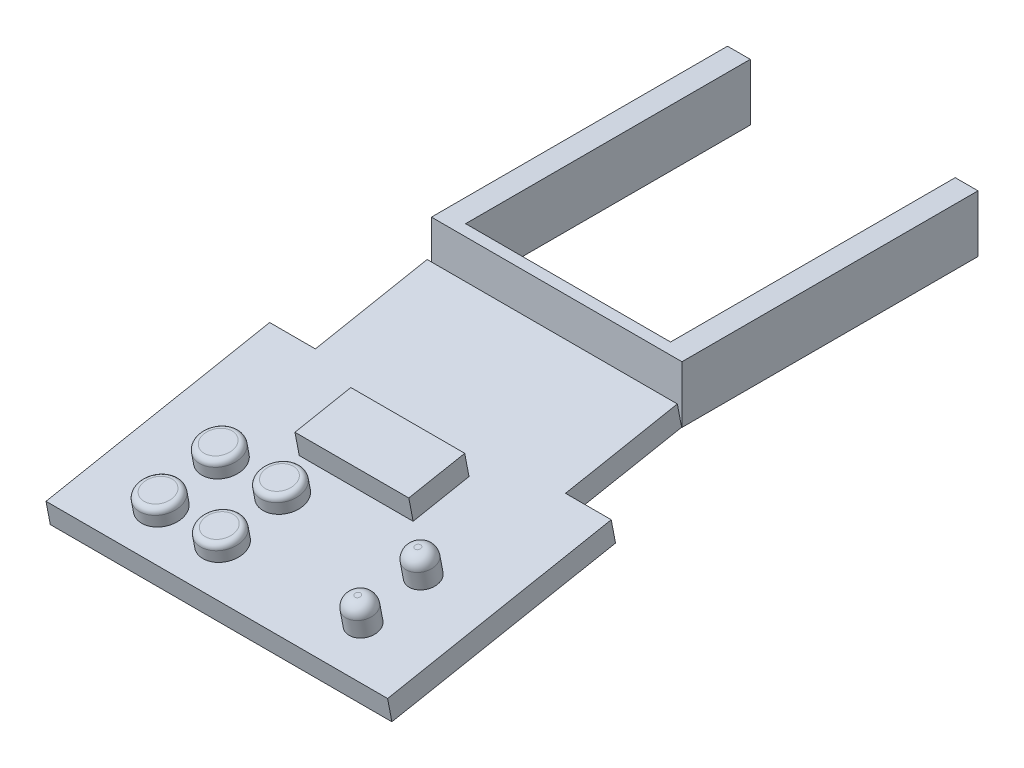
from build123d import *

# Parameters (mm, degrees)
SKETCH1_W             = 4
SKETCH1_H             = 50
BOSS_EXTRUDE1_DEPTH   = 10
BOSS_EXTRUDE1_2_DEPTH = 10
SKETCH2_W             = 44
SKETCH2_H             = 10
BOSS_EXTRUDE2_DEPTH   = 2
BOSS_EXTRUDE3_DEPTH   = 4
SKETCH4_W             = 20
SKETCH4_H             = 10
BOSS_EXTRUDE4_DEPTH   = 4
SKETCH4_3_R           = 3.5
BOSS_EXTRUDE5_DEPTH   = 3
SKETCH4_4_R           = 3.5
BOSS_EXTRUDE6_DEPTH   = 3
SKETCH4_5_R           = 2.5
BOSS_EXTRUDE7_DEPTH   = 5
FILLET1_R             = 2
FILLET2_R             = 1


with BuildPart() as part:
    # Sketch1 → Boss-Extrude1 (new body)
    with BuildSketch(Plane(origin=(0, 0, 0), x_dir=(1, 0, 0), z_dir=(0, 1, 0))):
        with Locations((20, -1.777777778)):
            Rectangle(SKETCH1_W, SKETCH1_H)
    extrude(amount=BOSS_EXTRUDE1_DEPTH)



with BuildPart() as body_2:
    # Sketch1 → Boss-Extrude1 2 (new body)
    with BuildSketch(Plane(origin=(0, 0, 0), x_dir=(1, 0, 0), z_dir=(0, 1, 0))):
        with Locations((-20, -1.777777778)):
            Rectangle(SKETCH1_W, SKETCH1_H)
    extrude(amount=BOSS_EXTRUDE1_2_DEPTH)


with BuildPart() as part_1:
    add(part.part)

    add(body_2.part)  # Boss-Extrude2 merges body 2
    # Sketch2 → Boss-Extrude2 (add)
    with BuildSketch(Plane.XY.offset(26.777777778)):
        with Locations((0, 5)):
            Rectangle(SKETCH2_W, SKETCH2_H)
    extrude(amount=BOSS_EXTRUDE2_DEPTH)


with BuildPart() as body_2_2:
    # Sketch3 → Boss-Extrude3 (new body)
    with BuildSketch(Plane(origin=(0, 5.336820415, 1.026311618), x_dir=(1, 0, 0), z_dir=(0, 0.9820064469806474, 0.18884739365012448))):
        Polygon((21.94373702, -28.259963308), (-22, -28.259963308), (-22, -48.259963308), (-30.02813149, -48.259963308), (-30.02813149, -88.259963308), (29.97186851, -88.259963308), (29.97186851, -48.259963308), (21.94373702, -48.259963308), align=None)
    extrude(amount=BOSS_EXTRUDE3_DEPTH)

    # Sketch4 → Boss-Extrude4 (add)
    with BuildSketch(Plane(origin=(0, 9.264846203, 1.781701193), x_dir=(1, 0, 0), z_dir=(0, 0.9820064469806474, 0.18884739365012448))):
        with Locations((-0.02813149, -58.327524377)):
            Rectangle(SKETCH4_W, SKETCH4_H)
    extrude(amount=BOSS_EXTRUDE4_DEPTH)

    # Sketch4_3 → Boss-Extrude5 (add)
    with BuildSketch(Plane(origin=(0, 9.264846203, 1.781701193), x_dir=(1, 0, 0), z_dir=(0, 0.9820064469806474, 0.18884739365012448))):
        with Locations((-6.694869848, -69.69133671)):
            Circle(SKETCH4_3_R)
    extrude(amount=BOSS_EXTRUDE5_DEPTH)

    # Sketch4_4 → Boss-Extrude6 (add)
    with BuildSketch(Plane(origin=(0, 9.264846203, 1.781701193), x_dir=(1, 0, 0), z_dir=(0, 0.9820064469806474, 0.18884739365012448))):
        with Locations((-17.452561289, -69.69133671)):
            Circle(SKETCH4_4_R)
        with Locations((-17.452561289, -80.449028151)):
            Circle(SKETCH4_4_R)
        with Locations((-6.694869848, -80.449028151)):
            Circle(SKETCH4_4_R)
    extrude(amount=BOSS_EXTRUDE6_DEPTH)

    # Sketch4_5 → Boss-Extrude7 (add)
    with BuildSketch(Plane(origin=(0, 9.264846203, 1.781701193), x_dir=(1, 0, 0), z_dir=(0, 0.9820064469806474, 0.18884739365012448))):
        with Locations((18.002365433, -69.69133671)):
            Circle(SKETCH4_5_R)
        with Locations((18.002365433, -80.449028151)):
            Circle(SKETCH4_5_R)
    extrude(amount=BOSS_EXTRUDE7_DEPTH)

    # Fillet1
    fillet1_edges = [body_2_2.edges().sort_by_distance(p)[0] for p in [
        (15.502365433, -1.01771085, 81.727402459),
        (15.502365433, 1.01385114, 71.163280109),
    ]]
    fillet(fillet1_edges, radius=FILLET1_R)

    # Fillet2
    fillet2_edges = [body_2_2.edges().sort_by_distance(p)[0] for p in [
        (-20.952561289, -2.981723744, 81.349707672),
        (-10.194869848, -2.981723744, 81.349707672),
        (-10.194869848, -0.950161753, 70.785585322),
        (-20.952561289, -0.950161753, 70.785585322),
    ]]
    fillet(fillet2_edges, radius=FILLET2_R)


solid = Compound([part_1.part, body_2_2.part])
